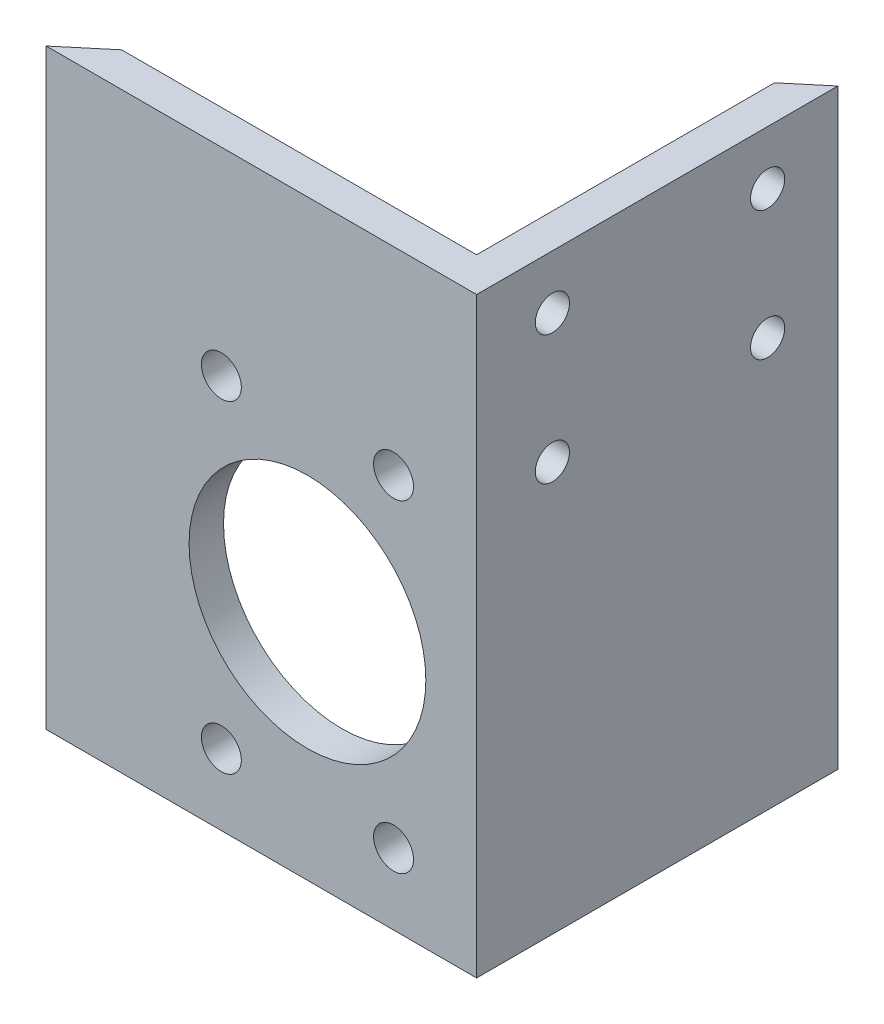
from build123d import *

# Parameters (mm, degrees)
BOSS_EXTRUDE1_DEPTH = 69.85
SKETCH2_R           = 2.0193
CUT_EXTRUDE1_DEPTH  = 5.064
SKETCH3_R           = 2.35585
SKETCH3_R_2         = 13.97
CUT_EXTRUDE2_DEPTH  = 5.064


with BuildPart() as part:
    # Sketch1 → Boss-Extrude1 (new body)
    with BuildSketch(Plane(origin=(0, 0, 0), x_dir=(1, 0, 0), z_dir=(0, 1, 0))):
        Polygon((0, 0), (50.8, 0), (50.8, 42.626261264), (46.736, 39.216160363), (46.736, 4.064), (4.8432866, 4.064), align=None)
    extrude(amount=BOSS_EXTRUDE1_DEPTH)

    # Sketch2 → Cut-Extrude1 (cut, through all)
    with BuildSketch(Plane.ZY.offset(-46.736)):
        with Locations((-34.340080181, 63.5)):
            Circle(SKETCH2_R)
        with Locations((-8.940080181, 63.5)):
            Circle(SKETCH2_R)
        with Locations((-8.940080181, 48.26)):
            Circle(SKETCH2_R)
        with Locations((-34.340080181, 48.26)):
            Circle(SKETCH2_R)
    extrude(amount=-CUT_EXTRUDE1_DEPTH, mode=Mode.SUBTRACT)

    # Sketch3 → Cut-Extrude2 (cut, through all)
    with BuildSketch(Plane(origin=(0, 0, -4.064), x_dir=(-1, 0, 0), z_dir=(0, 0, -1))):
        with Locations((-40.9956, 46.482)):
            Circle(SKETCH3_R)
        with Locations((-20.6756, 46.482)):
            Circle(SKETCH3_R)
        with Locations((-20.6756, 8.382)):
            Circle(SKETCH3_R)
        with Locations((-40.9956, 8.382)):
            Circle(SKETCH3_R)
        with Locations((-30.8356, 27.432)):
            Circle(SKETCH3_R_2)
    extrude(amount=-CUT_EXTRUDE2_DEPTH, mode=Mode.SUBTRACT)


solid = part.part
